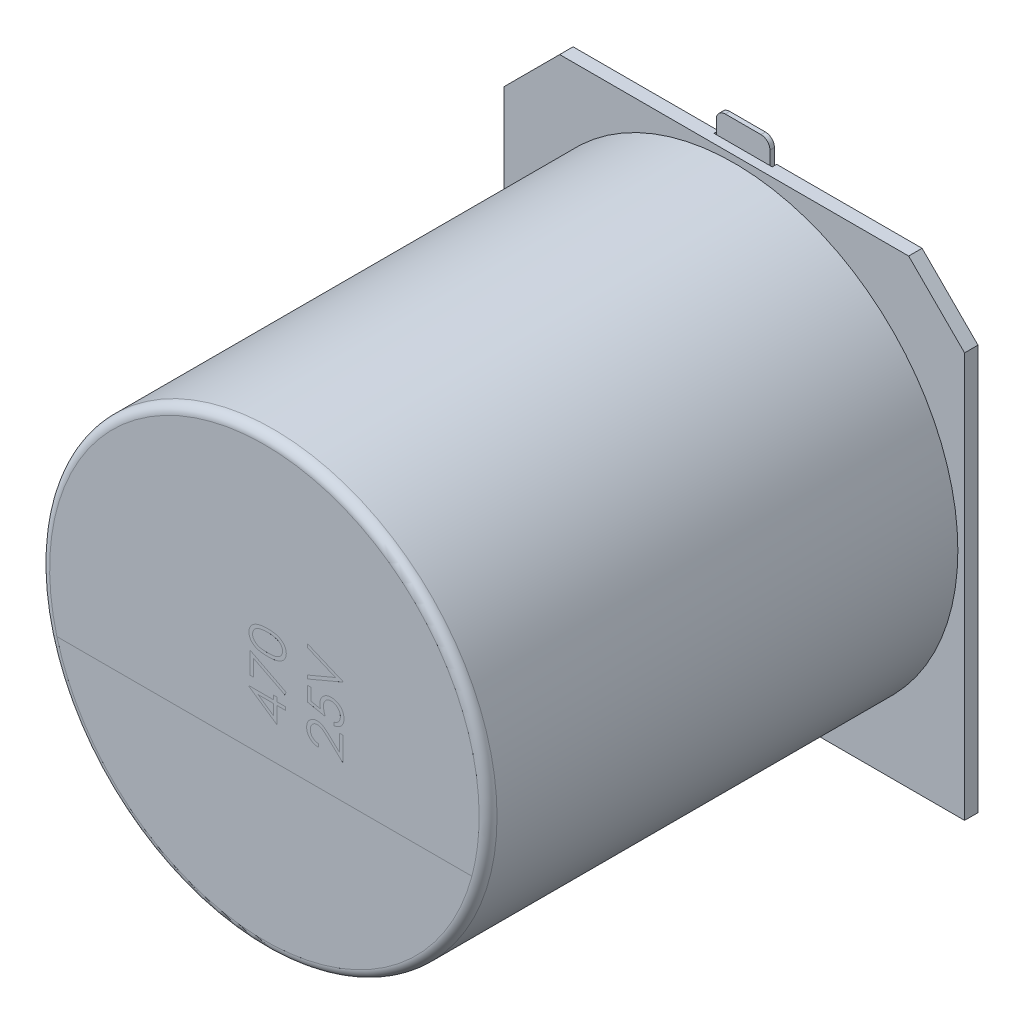
from build123d import *

# Parameters (mm, degrees)
RESSALTO_EXTRUS_O1_DEPTH   = 0.3
ESBO_O2_R                  = 5
RESSALTO_EXTRUS_O2_DEPTH   = 10.5
FILETE1_R                  = 0.2
CORTE_EXTRUS_O1_DEPTH      = 0.0001
CORTE_EXTRUS_O2_DEPTH      = 0.0001
ESBO_O5_W                  = 1.3
ESBO_O5_H                  = 3.2
CORTE_EXTRUS_O3_DEPTH      = 0.1
RESSALTO_EXTRUS_O3_DEPTH   = 0.1
RESSALTO_EXTRUS_O3_2_DEPTH = 0.1


with BuildPart() as part:
    # Esboço1 → Ressalto-extrusão1 (new body)
    with BuildSketch(Plane.XY):
        Polygon((-5.15, 3.9), (-3.9, 5.15), (3.9, 5.15), (5.15, 3.9), (5.15, -5.15), (-5.15, -5.15), align=None)
    extrude(amount=RESSALTO_EXTRUS_O1_DEPTH)

    # Esboço5 → Corte-extrusão3 (cut)
    with BuildSketch(Plane(origin=(0, 0, 0), x_dir=(-1, 0, 0), z_dir=(0, 0, -1))):
        with Locations((0, 4.05)):
            Rectangle(ESBO_O5_W, ESBO_O5_H)
        with Locations((0, -4.05)):
            Rectangle(ESBO_O5_W, ESBO_O5_H)
    extrude(amount=-CORTE_EXTRUS_O3_DEPTH, mode=Mode.SUBTRACT)


with BuildPart() as body_2:
    # Esboço2 → Ressalto-extrusão2 (new body)
    with BuildSketch(Plane.XY.offset(0.3)):
        Circle(ESBO_O2_R)
    extrude(amount=RESSALTO_EXTRUS_O2_DEPTH)

    # Filete1
    filete1_edges = [body_2.edges().sort_by_distance(p)[0] for p in [
        (-5, 0, 10.8),
    ]]
    fillet(filete1_edges, radius=FILETE1_R)

    # Esboço3 → Corte-extrusão1 (cut)
    with BuildSketch(Plane.XY.offset(10.8)):
        with BuildLine():
            Line((-4.638191195, -1.235792231), (4.638191195, -1.235792231))
            ThreePointArc((4.638191195, -1.235792231), (0, -4.8), (-4.638191195, -1.235792231))
        make_face()
    extrude(amount=-CORTE_EXTRUS_O1_DEPTH, mode=Mode.SUBTRACT)

    # Esboço4 → Corte-extrusão2 (cut)
    with BuildSketch(Plane.XY.offset(10.8)):
        Polygon((-0.345603573, -0.053115773), (-0.345603573, -0.038646372), (0.203915658, -0.038646372), (0.203915658, 0.052940167), (0.285325914, 0.052940167), (0.285325914, -0.038646372), (0.468498991, -0.038646372), (0.468498991, -0.109880346), (0.285325914, -0.109880346), (0.285325914, -0.486402782), align=None)
        Polygon((0.203915658, -0.109880346), (-0.140805897, -0.109880346), (0.203915658, -0.346478904), align=None, mode=Mode.SUBTRACT)
        Polygon((-0.325251009, 0.175055551), (-0.325251009, 0.66351709), (0.488851555, 0.246289526), (0.454983617, 0.18475482), (-0.243840752, 0.542991749), (-0.243840752, 0.175055551), align=None)
        with BuildLine():
            add(Edge.make_bspline(
                [(0.071942, 0.734751064), (0.059219914, 0.734825454), (0.034507078, 0.734969957), (-0.00150301, 0.73657751), (-0.035285076, 0.739247989), (-0.066840735, 0.742907715), (-0.096178136, 0.747361328), (-0.123218874, 0.753306628), (-0.148088112, 0.76006774), (-0.170866913, 0.76790376), (-0.191862285, 0.776745567), (-0.211462033, 0.786369287), (-0.229637975, 0.797155467), (-0.246674948, 0.808492502), (-0.262312749, 0.82082174), (-0.276731555, 0.833878818), (-0.28980977, 0.847924881), (-0.30155635, 0.862823694), (-0.311856387, 0.878474281), (-0.320984885, 0.894448969), (-0.328503981, 0.911033192), (-0.334654808, 0.928008628), (-0.339675871, 0.945411053), (-0.343124826, 0.963236025), (-0.345291044, 0.981524865), (-0.345498408, 0.993869064), (-0.345603573, 1.00012942)],
                knots=[0, 0, 0, 0, 3.8164e-05, 7.4134e-05, 0.00010811, 0.000139804, 0.000169422, 0.000197086, 0.000222816, 0.000246701, 0.000269292, 0.000291122, 0.000312148, 0.000332654, 0.000352471, 0.000371831, 0.000390956, 0.000409978, 0.000428677, 0.000447117, 0.000465119, 0.000483227, 0.000501246, 0.000519395, 0.000537639, 0.000556412, 0.000556412, 0.000556412, 0.000556412], degree=3))
            add(Edge.make_bspline(
                [(-0.345603573, 1.00012942), (-0.345515977, 1.00644517), (-0.345341692, 1.01901129), (-0.342888524, 1.037522708), (-0.339722149, 1.055711688), (-0.334643805, 1.073302268), (-0.328566908, 1.090627052), (-0.320548538, 1.107255208), (-0.311827939, 1.123773797), (-0.301189542, 1.139432401), (-0.289432362, 1.154698872), (-0.276084957, 1.169009594), (-0.261516717, 1.182730389), (-0.24540273, 1.195343026), (-0.227990069, 1.207388067), (-0.209132766, 1.218408268), (-0.188872613, 1.228632831), (-0.167303531, 1.238253949), (-0.143849378, 1.246667363), (-0.118656443, 1.254147561), (-0.091496591, 1.260278849), (-0.062521121, 1.265349316), (-0.031586489, 1.269284964), (0.001244629, 1.272149262), (0.035992772, 1.273662794), (0.059750363, 1.273947772), (0.071942, 1.274094013)],
                knots=[0, 0, 0, 0, 1.8932e-05, 3.7668e-05, 5.5944e-05, 7.4268e-05, 9.2526e-05, 0.00011095, 0.000129592, 0.000148511, 0.000167658, 0.000187349, 0.000207149, 0.000227636, 0.000248674, 0.000270626, 0.000293097, 0.000316733, 0.00034143, 0.000367793, 0.000395526, 0.000424908, 0.00045601, 0.000489049, 0.000523748, 0.000560324, 0.000560324, 0.000560324, 0.000560324], degree=3))
            add(Edge.make_bspline(
                [(0.071942, 1.274094013), (0.084080351, 1.273944554), (0.107784376, 1.273652688), (0.142377799, 1.272181723), (0.17503195, 1.269215002), (0.205781643, 1.265558146), (0.234641136, 1.260431007), (0.261591622, 1.254253228), (0.28672852, 1.247214567), (0.309871727, 1.23867203), (0.331403379, 1.229274851), (0.351514561, 1.21906126), (0.370366884, 1.208103247), (0.387825473, 1.196238854), (0.403874782, 1.183418752), (0.418492988, 1.169707575), (0.431925288, 1.155271903), (0.443811997, 1.139916431), (0.45453139, 1.124111976), (0.463568455, 1.107591709), (0.471398542, 1.090778428), (0.47780036, 1.073504269), (0.482765044, 1.055795901), (0.486177994, 1.037594454), (0.488577036, 1.019008678), (0.488759732, 1.006444296), (0.488851555, 1.00012942)],
                knots=[0, 0, 0, 0, 3.6418e-05, 7.1117e-05, 0.000103838, 0.000134762, 0.000163989, 0.000191722, 0.00021769, 0.000242238, 0.000265664, 0.000288135, 0.00030987, 0.000331039, 0.000351401, 0.000371426, 0.000391117, 0.000410488, 0.000429627, 0.000448345, 0.000466913, 0.000485226, 0.000503551, 0.000522012, 0.000540748, 0.00055968, 0.00055968, 0.00055968, 0.00055968], degree=3))
            add(Edge.make_bspline(
                [(0.488851555, 1.00012942), (0.488745793, 0.993869201), (0.488537249, 0.981525272), (0.486379671, 0.963234454), (0.482910869, 0.945481114), (0.47805389, 0.928177646), (0.472108737, 0.911235278), (0.464363177, 0.89488486), (0.455442746, 0.878944656), (0.445283883, 0.86345696), (0.433644479, 0.848713692), (0.420772596, 0.834628474), (0.406338155, 0.821568176), (0.390568411, 0.809345844), (0.373506091, 0.797888956), (0.355139743, 0.787195982), (0.335438006, 0.777370446), (0.314276706, 0.768377578), (0.291336231, 0.760404398), (0.266403599, 0.753388777), (0.239225568, 0.747785617), (0.209940125, 0.743036072), (0.178487766, 0.7392302), (0.144857112, 0.736578619), (0.109112023, 0.734971178), (0.084558104, 0.734825774), (0.071942, 0.734751064)],
                knots=[0, 0, 0, 0, 1.8773e-05, 3.7017e-05, 5.5166e-05, 7.2989e-05, 9.0894e-05, 0.000108962, 0.000127186, 0.000145664, 0.000164463, 0.00018348, 0.00020284, 0.000222782, 0.000243289, 0.000264451, 0.000286495, 0.000309294, 0.000333382, 0.000359307, 0.000386937, 0.00041658, 0.000448294, 0.000481952, 0.000517764, 0.00055561, 0.00055561, 0.00055561, 0.00055561], degree=3))
        make_face()
        with BuildLine():
            add(Edge.make_bspline(
                [(0.071623991, 0.805985039), (0.082225886, 0.806012722), (0.102802082, 0.806066449), (0.13264999, 0.80742941), (0.160535909, 0.809326513), (0.186448955, 0.811713177), (0.210298564, 0.815287547), (0.232183885, 0.819342888), (0.252064411, 0.824207022), (0.270113872, 0.829990544), (0.286587858, 0.836578538), (0.301925458, 0.843758841), (0.316308451, 0.85154088), (0.329701941, 0.860084171), (0.341942209, 0.86955762), (0.353339517, 0.879522037), (0.363497477, 0.890426314), (0.375682392, 0.905507742), (0.388273135, 0.925419045), (0.399237399, 0.950506088), (0.40612769, 0.976284493), (0.407003937, 0.993781291), (0.407441299, 1.002514486)],
                knots=[0, 0, 0, 0, 3.1802e-05, 6.1722e-05, 8.9613e-05, 0.000115656, 0.000139762, 0.000161934, 0.000182412, 0.000201117, 0.000218745, 0.000235603, 0.000251897, 0.000267775, 0.000283199, 0.000298292, 0.00031314, 0.000327841, 0.000356426, 0.000383485, 0.000409748, 0.000435919, 0.000435919, 0.000435919, 0.000435919], degree=3))
            add(Edge.make_bspline(
                [(0.407441299, 1.002514486), (0.407058336, 1.011298233), (0.40629377, 1.02883457), (0.399620933, 1.054589295), (0.388773019, 1.079385248), (0.376379534, 1.098953952), (0.364501248, 1.113800161), (0.354385544, 1.124441149), (0.343055639, 1.134206761), (0.330832223, 1.143469228), (0.317480736, 1.151964392), (0.303065666, 1.159689431), (0.287546902, 1.166738689), (0.276713408, 1.170754847), (0.271174522, 1.172808206)],
                knots=[0, 0, 0, 0, 2.6317e-05, 5.2541e-05, 7.9244e-05, 0.000107257, 0.000121734, 0.000136242, 0.00015123, 0.000166558, 0.000182216, 0.00019865, 0.000215586, 0.000233303, 0.000233303, 0.000233303, 0.000233303], degree=3))
            add(Edge.make_bspline(
                [(0.271174522, 1.172808206), (0.264092063, 1.175201196), (0.249711635, 1.180059992), (0.227404164, 1.186321948), (0.203999251, 1.191253494), (0.179636769, 1.195690186), (0.154137051, 1.198718468), (0.127578996, 1.201155919), (0.09994258, 1.202591628), (0.081165859, 1.202769599), (0.071623991, 1.202860039)],
                knots=[0, 0, 0, 0, 2.2426e-05, 4.5534e-05, 6.9455e-05, 9.4159e-05, 0.000119797, 0.000146458, 0.000174162, 0.000202787, 0.000202787, 0.000202787, 0.000202787], degree=3))
            add(Edge.make_bspline(
                [(0.071623991, 1.202860039), (0.062083667, 1.202735264), (0.043420753, 1.202491177), (0.016088951, 1.201558183), (-0.009870702, 1.199148908), (-0.034570041, 1.196473037), (-0.057872343, 1.192527596), (-0.079972678, 1.188273592), (-0.100597263, 1.182558323), (-0.120068967, 1.176453281), (-0.138166693, 1.169465998), (-0.154974374, 1.161774135), (-0.170574701, 1.153560465), (-0.184919474, 1.144635034), (-0.198091899, 1.135122162), (-0.209788879, 1.124680773), (-0.220579408, 1.113973972), (-0.232676388, 1.098746643), (-0.245108031, 1.078973493), (-0.256237175, 1.054199295), (-0.262823702, 1.028559068), (-0.263737107, 1.011189754), (-0.264193316, 1.002514486)],
                knots=[0, 0, 0, 0, 2.8625e-05, 5.5996e-05, 8.2009e-05, 0.000106821, 0.000130504, 0.000152893, 0.0001743, 0.000194666, 0.000214095, 0.000232453, 0.000250093, 0.000266947, 0.000283103, 0.000298764, 0.000313943, 0.000328644, 0.00035701, 0.000383778, 0.000409847, 0.00043586, 0.00043586, 0.00043586, 0.00043586], degree=3))
            add(Edge.make_bspline(
                [(-0.264193316, 1.002514486), (-0.263735972, 0.993734143), (-0.262820451, 0.976157462), (-0.256267635, 0.950243421), (-0.245140593, 0.925301858), (-0.232700339, 0.905463504), (-0.220625789, 0.890421162), (-0.210348957, 0.879746763), (-0.199223869, 0.869644153), (-0.186875016, 0.860416018), (-0.173528717, 0.851923386), (-0.159331722, 0.843840599), (-0.143965464, 0.836756316), (-0.127504396, 0.830147171), (-0.109453941, 0.824354003), (-0.089501481, 0.819545447), (-0.067563896, 0.815167825), (-0.043540029, 0.812015224), (-0.017621452, 0.80923915), (0.010335781, 0.807450237), (0.040286184, 0.806060205), (0.060968838, 0.806010596), (0.071623991, 0.805985039)],
                knots=[0, 0, 0, 0, 2.633e-05, 5.2708e-05, 7.9621e-05, 0.000107987, 0.000122688, 0.000137421, 0.000152395, 0.000167723, 0.000183601, 0.000199833, 0.000216691, 0.000234318, 0.000253024, 0.000273502, 0.00029586, 0.000320101, 0.000346159, 0.000374051, 0.000404129, 0.000436091, 0.000436091, 0.000436091, 0.000436091], degree=3))
        make_face(mode=Mode.SUBTRACT)
        with BuildLine():
            Line((1.208686588, -0.384639961), (1.208686588, -0.455873936))
            add(Edge.make_bspline(
                [(1.208686588, -0.455873936), (1.199236226, -0.455409671), (1.180675967, -0.454497866), (1.153615009, -0.450227879), (1.12774901, -0.444118073), (1.103285655, -0.435479476), (1.080008639, -0.424751088), (1.058010422, -0.411885528), (1.03737492, -0.396646923), (1.018293432, -0.379364324), (1.000788394, -0.360593579), (0.985671937, -0.340340268), (0.972899894, -0.319057556), (0.962222541, -0.296810014), (0.954207968, -0.273346636), (0.948261275, -0.248880345), (0.944683425, -0.223303648), (0.944298845, -0.205877429), (0.944103255, -0.197014761)],
                knots=[0, 0, 0, 0, 2.8367e-05, 5.5712e-05, 8.2052e-05, 0.000108001, 0.000133399, 0.000158842, 0.000184315, 0.00021021, 0.000235977, 0.000261195, 0.000285874, 0.00031034, 0.000335081, 0.00036011, 0.00038579, 0.000412367, 0.000412367, 0.000412367, 0.000412367], degree=3))
            add(Edge.make_bspline(
                [(0.944103255, -0.197014761), (0.944305358, -0.18831055), (0.944702485, -0.171207085), (0.948164181, -0.146255257), (0.953468922, -0.122445229), (0.961329712, -0.10004684), (0.971193285, -0.078830219), (0.983459929, -0.059058064), (0.99754923, -0.040252262), (1.01416825, -0.02333577), (1.031900787, -0.007795932), (1.050838988, 0.005598469), (1.07042167, 0.017133833), (1.090801804, 0.026575168), (1.112045757, 0.03373212), (1.133949855, 0.039034735), (1.156766887, 0.042065996), (1.172212925, 0.042528662), (1.180065795, 0.042763885)],
                knots=[0, 0, 0, 0, 2.61e-05, 5.1286e-05, 7.5432e-05, 9.9167e-05, 0.000122355, 0.000145481, 0.000168855, 0.000192695, 0.000216478, 0.000239509, 0.000262171, 0.000284582, 0.000306756, 0.000329318, 0.000352097, 0.000375656, 0.000375656, 0.000375656, 0.000375656], degree=3))
            add(Edge.make_bspline(
                [(1.180065795, 0.042763885), (1.191121103, 0.042379871), (1.213037713, 0.041618582), (1.245244725, 0.03510666), (1.276448681, 0.024935775), (1.301563175, 0.012691032), (1.321798141, 0.00033503), (1.338466838, -0.010788384), (1.35640982, -0.023884236), (1.375699712, -0.038840642), (1.396083895, -0.055915171), (1.417978262, -0.074664229), (1.440977972, -0.095572017), (1.456697317, -0.110233403), (1.464842688, -0.117830566)],
                knots=[0, 0, 0, 0, 3.3137e-05, 6.5693e-05, 9.8175e-05, 0.000131386, 0.00014922, 0.000169286, 0.000191485, 0.000215848, 0.000242498, 0.000271247, 0.000302319, 0.000335734, 0.000335734, 0.000335734, 0.000335734], degree=3))
            Line((1.464842688, -0.117830566), (1.676795562, -0.316427071))
            Line((1.676795562, -0.316427071), (1.676795562, 0.052940167))
            Line((1.676795562, 0.052940167), (1.758205819, 0.052940167))
            Line((1.758205819, 0.052940167), (1.758205819, -0.486402782))
            Line((1.758205819, -0.486402782), (1.429702714, -0.17857025))
            add(Edge.make_bspline(
                [(1.429702714, -0.17857025), (1.421878991, -0.171075461), (1.40685122, -0.156679506), (1.384911299, -0.1363181), (1.364557385, -0.11803033), (1.345827936, -0.101697814), (1.328448991, -0.087674858), (1.312983406, -0.07523062), (1.298751593, -0.065259852), (1.282255061, -0.054438682), (1.262113696, -0.043958011), (1.237499806, -0.034951816), (1.212161661, -0.029460234), (1.195038878, -0.028801459), (1.186425971, -0.02847009)],
                knots=[0, 0, 0, 0, 3.2503e-05, 6.2431e-05, 8.9791e-05, 0.000114592, 0.000136967, 0.000156784, 0.000174122, 0.000189073, 0.000215956, 0.000242011, 0.000267521, 0.000293339, 0.000293339, 0.000293339, 0.000293339], degree=3))
            add(Edge.make_bspline(
                [(1.186425971, -0.02847009), (1.181010011, -0.028614267), (1.170336194, -0.028898413), (1.154686674, -0.03140614), (1.139590725, -0.035195844), (1.125001913, -0.040626287), (1.111066917, -0.047794244), (1.097768774, -0.056519457), (1.084912527, -0.066586489), (1.072858118, -0.078232223), (1.061817916, -0.09102555), (1.052037989, -0.104540675), (1.043864834, -0.118839538), (1.037164791, -0.133861851), (1.031908945, -0.149565734), (1.028267089, -0.16598156), (1.025980526, -0.183063971), (1.025671151, -0.194728353), (1.025513511, -0.200671862)],
                knots=[0, 0, 0, 0, 1.6238e-05, 3.2002e-05, 4.7428e-05, 6.2874e-05, 7.859e-05, 9.4334e-05, 0.000110526, 0.000127506, 0.000144529, 0.000161164, 0.000177474, 0.000193845, 0.000210438, 0.000227064, 0.000244222, 0.000262048, 0.000262048, 0.000262048, 0.000262048], degree=3))
            add(Edge.make_bspline(
                [(1.025513511, -0.200671862), (1.025669272, -0.206880734), (1.02597516, -0.219073933), (1.028292108, -0.23693825), (1.031804603, -0.254097705), (1.037383212, -0.270296265), (1.043974615, -0.285884699), (1.052348282, -0.300530217), (1.06207867, -0.314475982), (1.073361451, -0.327492612), (1.086038472, -0.339380937), (1.100009424, -0.349973264), (1.115173727, -0.359167402), (1.131469144, -0.367200405), (1.149057917, -0.373721028), (1.167873614, -0.378704439), (1.18783566, -0.382647468), (1.201620841, -0.383964766), (1.208686588, -0.384639961)],
                knots=[0, 0, 0, 0, 1.862e-05, 3.6568e-05, 5.397e-05, 7.1065e-05, 8.7873e-05, 0.000104676, 0.000121571, 0.000138818, 0.000156254, 0.000173617, 0.000191315, 0.000209378, 0.000228044, 0.000247484, 0.000267722, 0.000289004, 0.000289004, 0.000289004, 0.000289004], degree=3))
        make_face()
        with BuildLine():
            Line((0.964455819, 0.622811962), (1.045866075, 0.622811962))
            Line((1.045866075, 0.622811962), (1.045866075, 0.352822479))
            Line((1.045866075, 0.352822479), (1.254638862, 0.310050293))
            add(Edge.make_bspline(
                [(1.254638862, 0.310050293), (1.252318782, 0.318454036), (1.247823995, 0.334734959), (1.242833401, 0.358765142), (1.239824988, 0.381578016), (1.239414208, 0.396381538), (1.239215434, 0.403544884)],
                knots=[0, 0, 0, 0, 2.6149e-05, 5.0659e-05, 7.3576e-05, 9.5063e-05, 9.5063e-05, 9.5063e-05, 9.5063e-05], degree=3))
            add(Edge.make_bspline(
                [(1.239215434, 0.403544884), (1.239400945, 0.412410145), (1.239765704, 0.429841463), (1.243476183, 0.455305939), (1.248850508, 0.47973696), (1.257130674, 0.502773804), (1.267242233, 0.524780936), (1.279977962, 0.545380411), (1.294846895, 0.564861343), (1.311772453, 0.583089091), (1.33059354, 0.59954761), (1.350913659, 0.613849521), (1.372289391, 0.626332436), (1.395221738, 0.636067989), (1.419278191, 0.644013151), (1.44473644, 0.64925221), (1.471370474, 0.652751674), (1.489582615, 0.653141846), (1.498869631, 0.653340808)],
                knots=[0, 0, 0, 0, 2.6577e-05, 5.2257e-05, 7.7058e-05, 0.000101498, 0.000125542, 0.000149594, 0.000173986, 0.000198962, 0.000224092, 0.000248842, 0.000273416, 0.000298198, 0.00032344, 0.000349294, 0.000376057, 0.000403905, 0.000403905, 0.000403905, 0.000403905], degree=3))
            add(Edge.make_bspline(
                [(1.498869631, 0.653340808), (1.505338023, 0.653189842), (1.518187391, 0.652889952), (1.537270687, 0.651368264), (1.555947196, 0.648427218), (1.57418268, 0.644526477), (1.591994217, 0.639319181), (1.609481532, 0.633228301), (1.626453142, 0.625657741), (1.642984003, 0.617264929), (1.658884924, 0.607971472), (1.673774653, 0.597521185), (1.687992976, 0.586662736), (1.701117631, 0.574797875), (1.713199525, 0.5620615), (1.72429839, 0.548524478), (1.734613416, 0.53430959), (1.74372285, 0.519192954), (1.752105558, 0.503512475), (1.758982493, 0.48704142), (1.765130776, 0.470154801), (1.770031508, 0.452609551), (1.773871569, 0.434445419), (1.776479741, 0.415632461), (1.778379398, 0.396269345), (1.778498314, 0.383144119), (1.778558383, 0.376514135)],
                knots=[0, 0, 0, 0, 1.9409e-05, 3.8556e-05, 5.7378e-05, 7.6091e-05, 9.4459e-05, 0.000113016, 0.000131599, 0.000150159, 0.00016862, 0.000186792, 0.000204698, 0.000222261, 0.000239806, 0.000257315, 0.000274745, 0.000292443, 0.000310224, 0.000328033, 0.000345938, 0.00036411, 0.000382634, 0.00040159, 0.000421067, 0.000440948, 0.000440948, 0.000440948, 0.000440948], degree=3))
            add(Edge.make_bspline(
                [(1.778558383, 0.376514135), (1.778401289, 0.368605371), (1.778092226, 0.353045811), (1.774873683, 0.330246308), (1.770233505, 0.308323315), (1.763358828, 0.287370792), (1.754356929, 0.267476122), (1.743661311, 0.248354419), (1.730928342, 0.230242686), (1.716274485, 0.21326475), (1.700172983, 0.197658263), (1.682867024, 0.183506186), (1.664334566, 0.171063896), (1.644635871, 0.160286262), (1.623805881, 0.151104699), (1.601780413, 0.143888739), (1.578670772, 0.138065468), (1.562760982, 0.13560177), (1.554680178, 0.134350423)],
                knots=[0, 0, 0, 0, 2.3711e-05, 4.6648e-05, 6.8948e-05, 9.0871e-05, 0.00011265, 0.000134364, 0.000156509, 0.000178947, 0.000201548, 0.000223699, 0.000245926, 0.000268413, 0.000290983, 0.000314112, 0.000337868, 0.000362388, 0.000362388, 0.000362388, 0.000362388], degree=3))
            Line((1.554680178, 0.134350423), (1.554680178, 0.205584398))
            add(Edge.make_bspline(
                [(1.554680178, 0.205584398), (1.562250269, 0.207336028), (1.576800403, 0.210702757), (1.597230416, 0.218111867), (1.615442484, 0.227082822), (1.631547957, 0.237998912), (1.645841643, 0.250652057), (1.658444355, 0.265360684), (1.669828044, 0.281757082), (1.679333202, 0.299986657), (1.687340015, 0.3192562), (1.693053939, 0.339309296), (1.696512701, 0.359857341), (1.696935521, 0.373691864), (1.697148127, 0.38064825)],
                knots=[0, 0, 0, 0, 2.3293e-05, 4.477e-05, 6.5036e-05, 8.4044e-05, 0.000102966, 0.000122127, 0.000142019, 0.000162717, 0.000183682, 0.000204518, 0.000225143, 0.000246002, 0.000246002, 0.000246002, 0.000246002], degree=3))
            add(Edge.make_bspline(
                [(1.697148127, 0.38064825), (1.696960428, 0.387441821), (1.696590849, 0.400818417), (1.693792198, 0.420514266), (1.689368736, 0.43947429), (1.68317172, 0.457732145), (1.67497343, 0.475198115), (1.664902304, 0.491847506), (1.653209606, 0.507917502), (1.63984528, 0.522985166), (1.62510942, 0.536781957), (1.609353374, 0.548973267), (1.592544618, 0.559127982), (1.574974844, 0.567685552), (1.556451306, 0.574183707), (1.537060863, 0.57881943), (1.516755608, 0.581541552), (1.502905961, 0.581916017), (1.495848547, 0.582106834)],
                knots=[0, 0, 0, 0, 2.0375e-05, 4.0118e-05, 5.9557e-05, 7.8715e-05, 9.7849e-05, 0.000117319, 0.000137006, 0.000157394, 0.000177643, 0.000197488, 0.00021704, 0.000236455, 0.000256018, 0.000275802, 0.000296176, 0.000317345, 0.000317345, 0.000317345, 0.000317345], degree=3))
            add(Edge.make_bspline(
                [(1.495848547, 0.582106834), (1.489480615, 0.581962037), (1.477068857, 0.581679814), (1.458846477, 0.579236628), (1.441577021, 0.575155324), (1.425185347, 0.569344376), (1.409723862, 0.562092128), (1.39522664, 0.55298671), (1.381557368, 0.542415839), (1.369067815, 0.530074587), (1.357522386, 0.51664986), (1.347715902, 0.501796841), (1.339376284, 0.485912052), (1.332543442, 0.468966056), (1.32710056, 0.450937978), (1.32333891, 0.431818109), (1.321087995, 0.411602091), (1.320782647, 0.397773686), (1.320625691, 0.390665527)],
                knots=[0, 0, 0, 0, 1.9097e-05, 3.7222e-05, 5.504e-05, 7.2239e-05, 8.9309e-05, 0.000106163, 0.000123498, 0.000141039, 0.000158751, 0.000176523, 0.000194304, 0.000212492, 0.000231256, 0.000250714, 0.000270872, 0.000292193, 0.000292193, 0.000292193, 0.000292193], degree=3))
            add(Edge.make_bspline(
                [(1.320625691, 0.390665527), (1.32075736, 0.384513074), (1.321029225, 0.371809818), (1.323030949, 0.352323749), (1.326260217, 0.331846876), (1.330702098, 0.310457696), (1.33651486, 0.288091973), (1.34348047, 0.264796907), (1.351808495, 0.240523518), (1.358097765, 0.224168249), (1.361330819, 0.21576068)],
                knots=[0, 0, 0, 0, 1.8455e-05, 3.8106e-05, 5.8705e-05, 8.0628e-05, 0.000103613, 0.000128011, 0.000153555, 0.000180577, 0.000180577, 0.000180577, 0.000180577], degree=3))
            Line((1.361330819, 0.21576068), (0.964455819, 0.297170936))
            Line((0.964455819, 0.297170936), (0.964455819, 0.622811962))
        make_face()
        Polygon((0.964455819, 0.744927346), (0.964455819, 0.821249462), (1.589979156, 1.085832795), (0.964455819, 1.350416128), (0.964455819, 1.426738244), (1.758205819, 1.090920936), (1.758205819, 1.080744654), align=None)
    extrude(amount=-CORTE_EXTRUS_O2_DEPTH, mode=Mode.SUBTRACT)


with BuildPart() as body_3:
    # Esboço6 → Ressalto-extrusão3 (new body)
    with BuildSketch(Plane(origin=(0, 0, 0.1), x_dir=(-1, 0, 0), z_dir=(0, 0, -1))):
        with BuildLine():
            Line((-0.4, 5.65), (0.4, 5.65))
            ThreePointArc((0.4, 5.65), (0.541421356, 5.591421356), (0.6, 5.45))
            Line((0.6, 5.45), (0.6, 2.45))
            Line((0.6, 2.45), (-0.6, 2.45))
            Line((-0.6, 2.45), (-0.6, 5.45))
            ThreePointArc((-0.6, 5.45), (-0.541421356, 5.591421356), (-0.4, 5.65))
        make_face()
    extrude(amount=RESSALTO_EXTRUS_O3_DEPTH)


with BuildPart() as body_4:
    # Esboço6 → Ressalto-extrus_o3 2 (new body)
    with BuildSketch(Plane(origin=(0, 0, 0.1), x_dir=(-1, 0, 0), z_dir=(0, 0, -1))):
        with BuildLine():
            Line((-0.6, -2.45), (0.6, -2.45))
            Line((0.6, -2.45), (0.6, -5.45))
            ThreePointArc((0.6, -5.45), (0.541421356, -5.591421356), (0.4, -5.65))
            Line((0.4, -5.65), (-0.4, -5.65))
            ThreePointArc((-0.4, -5.65), (-0.541421356, -5.591421356), (-0.6, -5.45))
            Line((-0.6, -5.45), (-0.6, -2.45))
        make_face()
    extrude(amount=RESSALTO_EXTRUS_O3_2_DEPTH)


solid = Compound([part.part, body_2.part, body_3.part, body_4.part])
